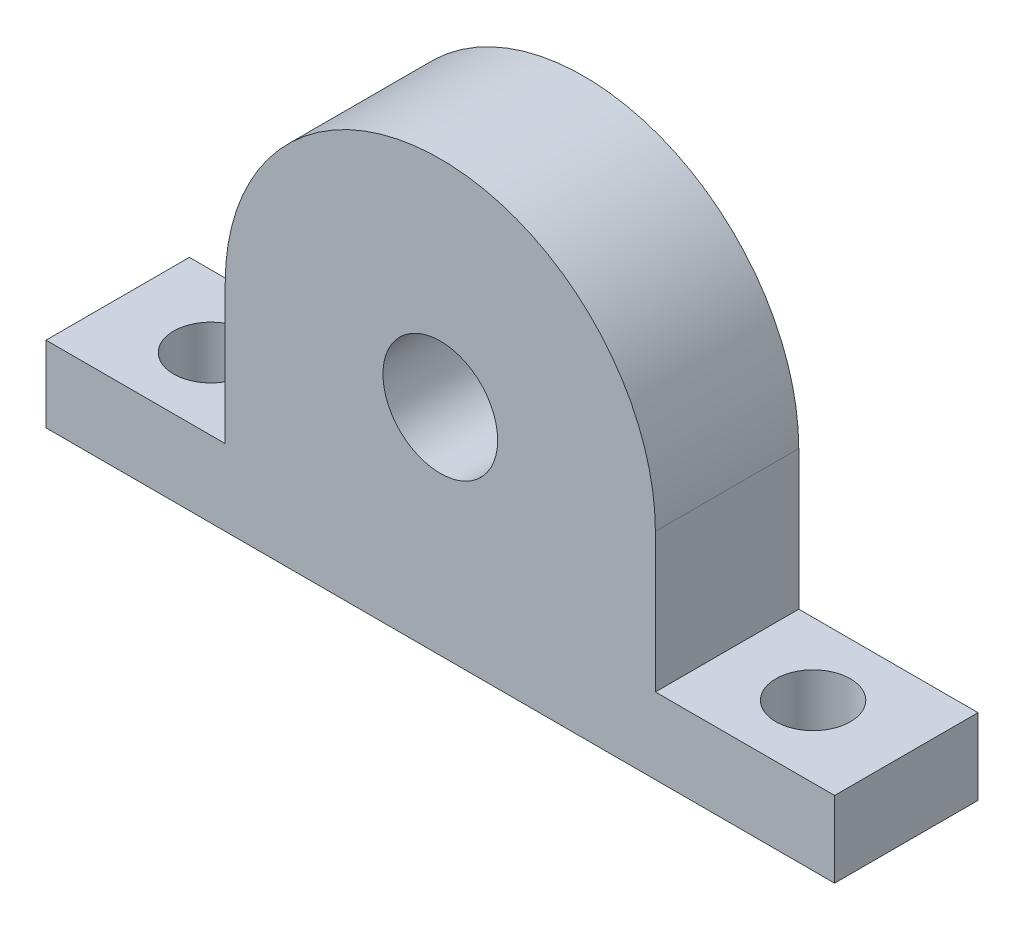
from build123d import *

# Parameters (mm, degrees)
SKETCH_1_R          = 4
EXTRUDE_1_DEPTH     = 10
SKETCH_2_R          = 2.6
CUT_EXTRUDE_1_DEPTH = 10


with BuildPart() as part:
    # 草图1 → 凸台-拉伸1 (new body)
    with BuildSketch(Plane.XY):
        with BuildLine():
            Line((-27.5, -15), (27.5, -15))
            Line((27.5, -15), (27.5, -9.7))
            Line((27.5, -9.7), (15, -9.7))
            Line((15, -9.7), (15, 0))
            ThreePointArc((15, 0), (0, 15), (-15, 0))
            Line((-15, 0), (-15, -9.7))
            Line((-15, -9.7), (-27.5, -9.7))
            Line((-27.5, -9.7), (-27.5, -15))
        make_face()
        Circle(SKETCH_1_R, mode=Mode.SUBTRACT)
    extrude(amount=EXTRUDE_1_DEPTH)

    # 草图2 → 切除-拉伸1 (cut)
    with BuildSketch(Plane(origin=(0, -9.7, 0), x_dir=(1, 0, 0), z_dir=(0, 1, 0))):
        with Locations((21, -5)):
            Circle(SKETCH_2_R)
        with Locations((-21, -5)):
            Circle(SKETCH_2_R)
    extrude(amount=-CUT_EXTRUDE_1_DEPTH, mode=Mode.SUBTRACT)


solid = part.part
